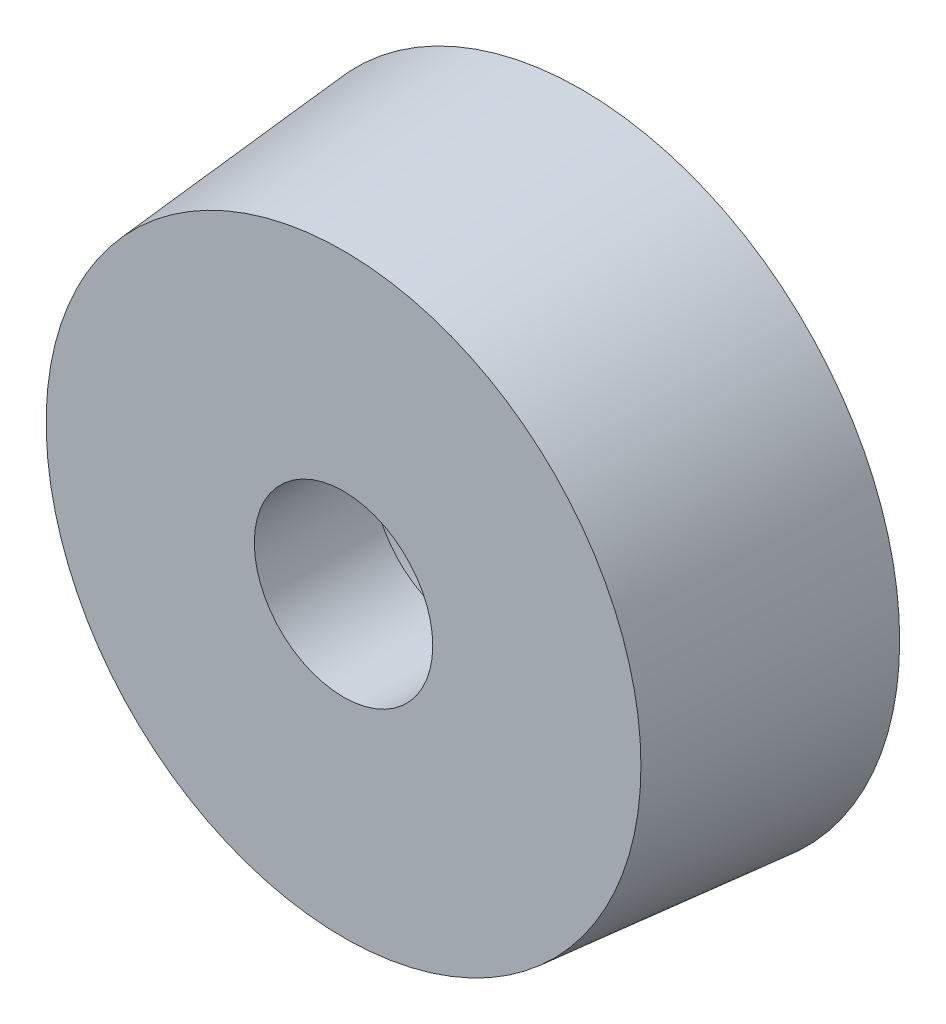
from build123d import *

# Parameters (mm, degrees)
SKETCH_1_R          = 10
SKETCH_1_R_2        = 3
EXTRUDE_1_DEPTH     = 8
DRAFT_1_ANGLE       = 5
SKETCH_2_R          = 6
CUT_EXTRUDE_1_DEPTH = 4


with BuildPart() as part:
    # 草图1 → 凸台-拉伸1 (new body)
    with BuildSketch(Plane.XY):
        Circle(SKETCH_1_R)
        Circle(SKETCH_1_R_2, mode=Mode.SUBTRACT)
    extrude(amount=EXTRUDE_1_DEPTH)

    # 拔模1
    draft_1_faces = [part.faces().sort_by_distance(p)[0] for p in [
        (-10, 0, 4),
    ]]
    draft(draft_1_faces, Plane.XY.offset(8), DRAFT_1_ANGLE)

    # 草图2 → 切除-拉伸1 (cut)
    with BuildSketch(Plane(origin=(0, 0, 0), x_dir=(-1, 0, 0), z_dir=(0, 0, -1))):
        Circle(SKETCH_2_R)
    extrude(amount=-CUT_EXTRUDE_1_DEPTH, mode=Mode.SUBTRACT)


solid = part.part
